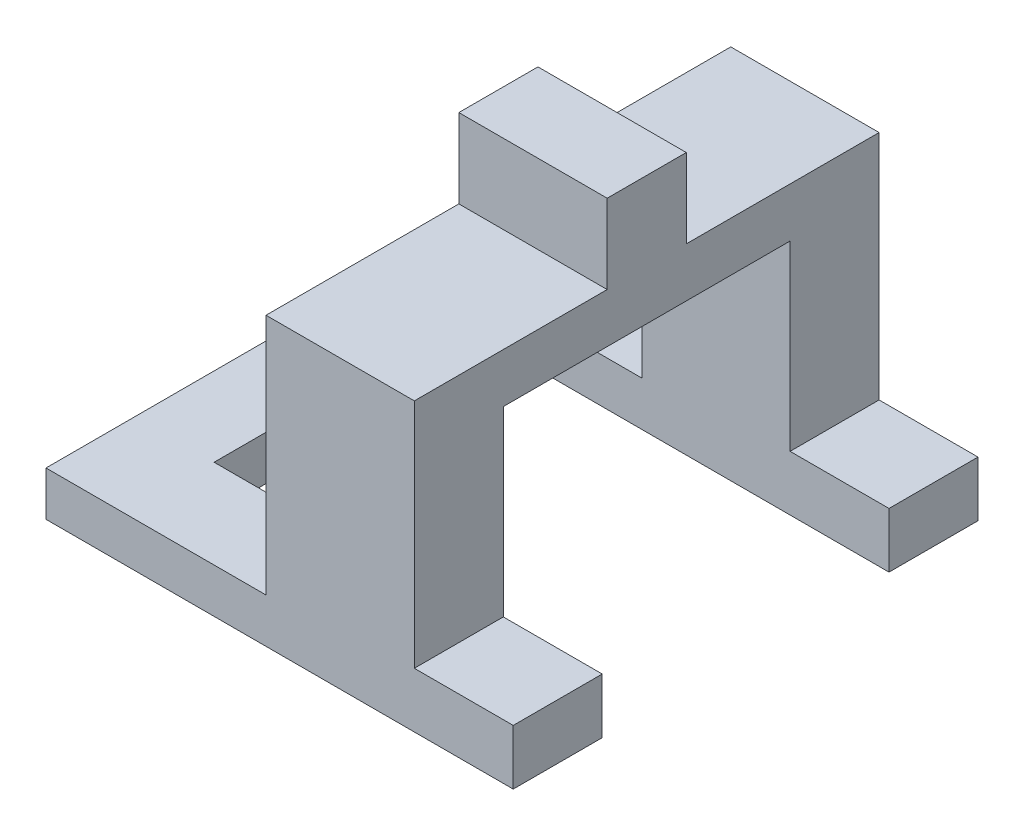
from build123d import *

# Parameters (mm, degrees)
BOSS_EXTRUDE1_DEPTH = 47
SKETCH2_W           = 8
SKETCH2_H           = 8
BOSS_EXTRUDE2_DEPTH = 15
SKETCH4_W           = 29
SKETCH4_H           = 18.42
CUT_EXTRUDE4_DEPTH  = 15
SKETCH5_W           = 29
SKETCH5_H           = 5.58
CUT_EXTRUDE5_DEPTH  = 39.25
SKETCH7_R           = 1.4
CUT_EXTRUDE6_DEPTH  = 39.25


with BuildPart() as part:
    # Sketch1 → Boss-Extrude1 (new body)
    with BuildSketch(Plane.XY):
        Polygon((-6.810719807, 3.369565217), (-6.810719807, -21.130434783), (-29.058309823, -21.130434783), (-29.058309823, -25.630434783), (18.189280193, -25.630434783), (18.189280193, -20.050434783), (8.189280193, -20.050434783), (8.189280193, 3.369565217), align=None)
    extrude(amount=BOSS_EXTRUDE1_DEPTH)

    # Sketch2 → Boss-Extrude2 (add)
    with BuildSketch(Plane(origin=(8.189280193, 0, 0), x_dir=(0, 0, -1), z_dir=(1, 0, 0))):
        with Locations((-23.5, 7.369565217)):
            Rectangle(SKETCH2_W, SKETCH2_H)
    extrude(amount=-BOSS_EXTRUDE2_DEPTH)

    # Sketch4 → Cut-Extrude4 (cut)
    with BuildSketch(Plane(origin=(8.189280193, 0, 0), x_dir=(0, 0, -1), z_dir=(1, 0, 0))):
        with Locations((-23.5, -10.840434783)):
            Rectangle(SKETCH4_W, SKETCH4_H)
    extrude(amount=-CUT_EXTRUDE4_DEPTH, mode=Mode.SUBTRACT)

    # Sketch5 → Cut-Extrude5 (cut)
    with BuildSketch(Plane(origin=(18.189280193, 0, 0), x_dir=(0, 0, -1), z_dir=(1, 0, 0))):
        with Locations((-23.5, -22.840434783)):
            Rectangle(SKETCH5_W, SKETCH5_H)
    extrude(amount=-CUT_EXTRUDE5_DEPTH, mode=Mode.SUBTRACT)

    # Sketch7 → Cut-Extrude6 (cut)
    with BuildSketch(Plane(origin=(0, -21.130434783, 0), x_dir=(1, 0, 0), z_dir=(0, 1, 0))):
        with Locations((-25.059514815, -23.5)):
            Circle(SKETCH7_R)
    extrude(amount=-CUT_EXTRUDE6_DEPTH, mode=Mode.SUBTRACT)


solid = part.part
